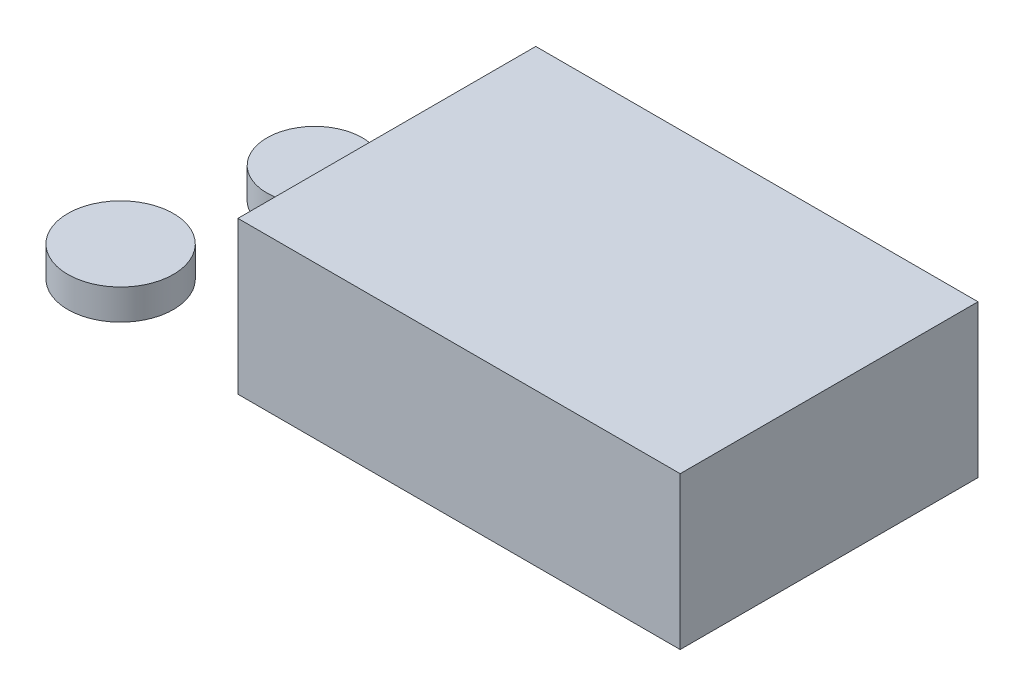
from build123d import *

# Parameters (mm, degrees)
SKETCH_1_W      = 145.162550348
SKETCH_1_H      = 97.757068038
EXTRUDE_1_DEPTH = 50
SKETCH_2_R      = 15.69817808
EXTRUDE_2_DEPTH = 10
SKETCH_3_R      = 17.334319562
EXTRUDE_3_DEPTH = 10


with BuildPart() as part:
    # 草图1 → 凸台-拉伸1 (new body)
    with BuildSketch(Plane(origin=(0, 0, 0), x_dir=(1, 0, 0), z_dir=(0, 1, 0))):
        Rectangle(SKETCH_1_W, SKETCH_1_H)
    extrude(amount=EXTRUDE_1_DEPTH)


with BuildPart() as body_2:
    # 草图2 → 凸台-拉伸2 (new body)
    with BuildSketch(Plane(origin=(0, 0, 0), x_dir=(1, 0, 0), z_dir=(0, 1, 0))):
        with Locations((-115.030740926, 18.785262127)):
            Circle(SKETCH_2_R)
    extrude(amount=EXTRUDE_2_DEPTH)


with BuildPart() as body_3:
    # 草图3 → 凸台-拉伸3 (new body)
    with BuildSketch(Plane(origin=(0, 0, 0), x_dir=(1, 0, 0), z_dir=(0, 1, 0))):
        with Locations((-124.569592284, -35.404894456)):
            Circle(SKETCH_3_R)
    extrude(amount=EXTRUDE_3_DEPTH)


solid = Compound([part.part, body_2.part, body_3.part])
